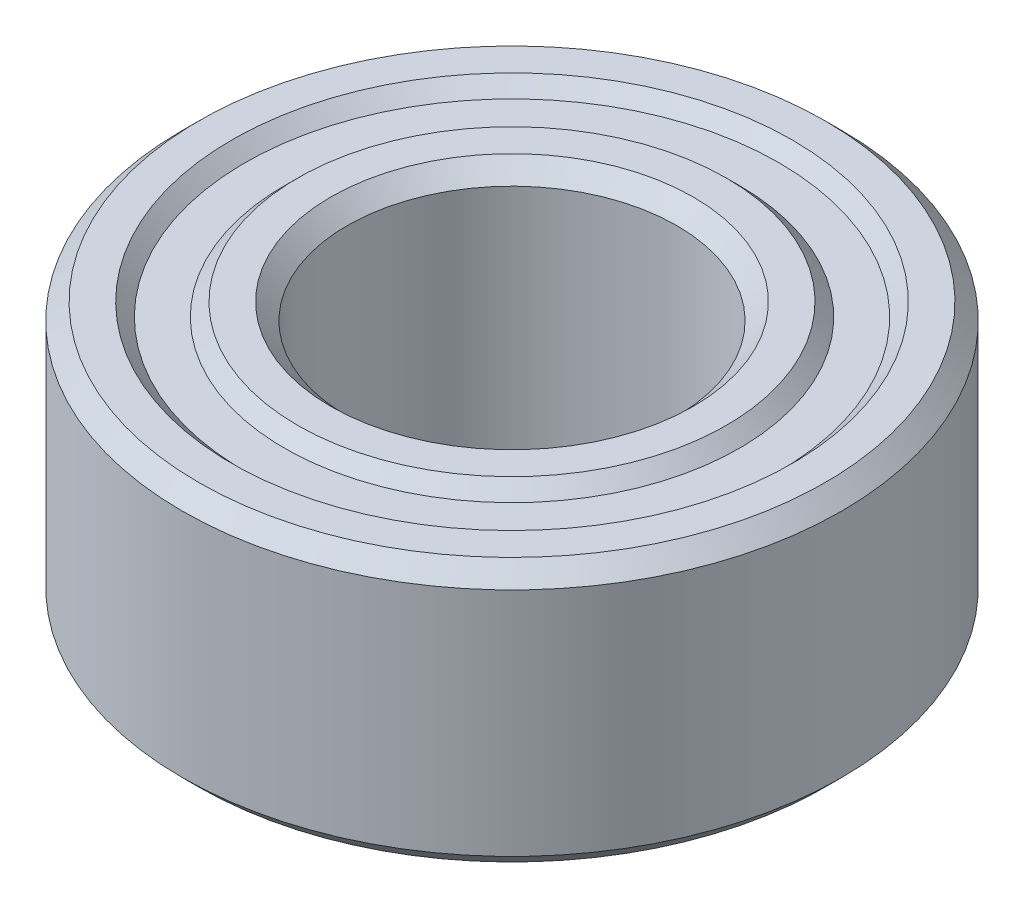
from build123d import *


with BuildPart() as part:
    # Sketch1 → Revolve1 (revolve)
    with BuildSketch(Plane.XY):
        Polygon((2.5, 1.75), (2.5, -1.75), (2.75, -2), (3.25, -2), (3.45, -1.8), (4.05, -1.8), (4.25, -2), (4.75, -2), (5, -1.75), (5, 1.75), (4.75, 2), (4.25, 2), (4.05, 1.8), (3.45, 1.8), (3.25, 2), (2.75, 2), align=None)
    revolve(axis=Axis((0, -1.349421972, 0), (0, 1, 0)))


solid = part.part
